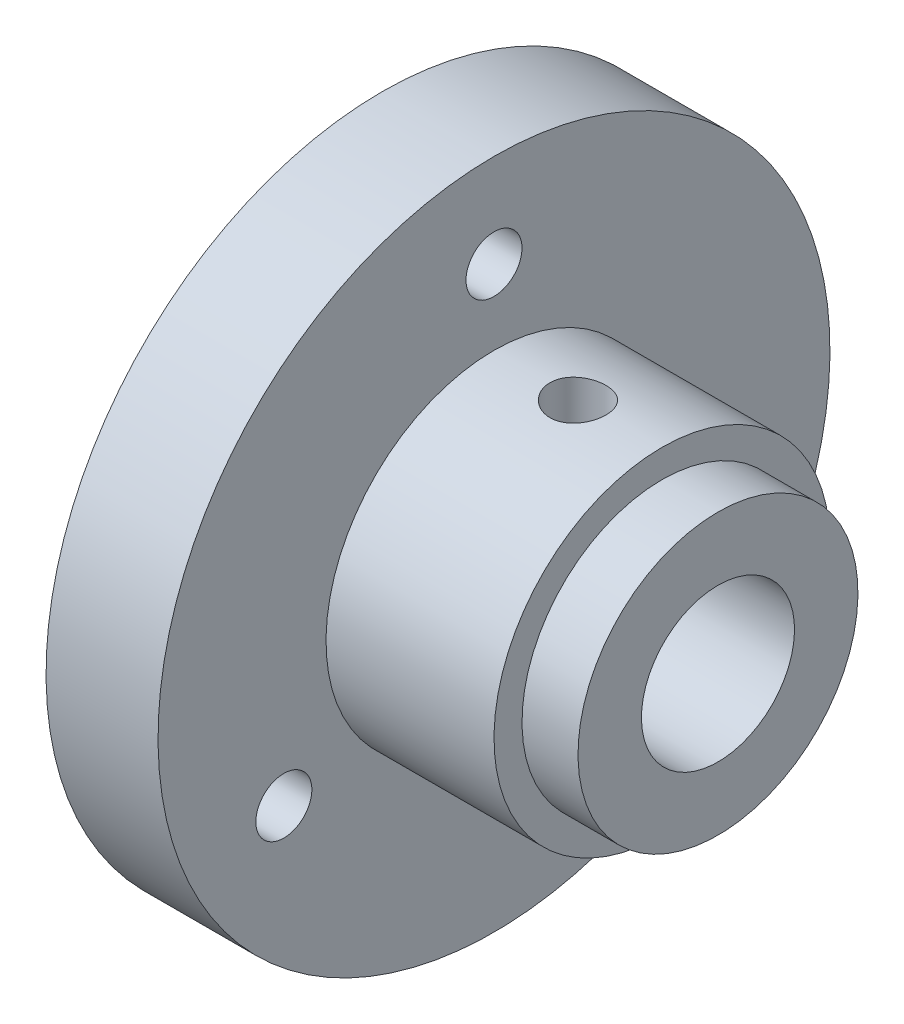
from build123d import *

# Parameters (mm, degrees)
ESQUISSE2_R             = 1.5
ENL_V_MAT_EXTRU_1_DEPTH = 7
ENL_V_MAT_EXTRU_2_REACH = 29
ESQUISSE3_R             = 1.5


with BuildPart() as part:
    # Esquisse1 → Révolution1 (revolve)
    with BuildSketch(Plane.XY):
        Polygon((0, 4.1), (-18, 4.1), (-18, 18), (-12, 18), (-12, 9), (-3, 9), (-3, 7.5), (0, 7.5), align=None)
    revolve(axis=Axis((0, 0, 0), (-1, 0, 0)))

    # Esquisse2 → Enlèv. mat.-Extru.1 (cut, through all)
    with BuildSketch(Plane(origin=(-12, 0, 0), x_dir=(0, 0, -1), z_dir=(1, 0, 0))):
        with Locations((0, 13)):
            Circle(ESQUISSE2_R)
        with Locations((11.258330249, -6.5)):
            Circle(ESQUISSE2_R)
        with Locations((-11.258330249, -6.5)):
            Circle(ESQUISSE2_R)
    extrude(amount=-ENL_V_MAT_EXTRU_1_DEPTH, mode=Mode.SUBTRACT)

    # Esquisse3 → Enlèv. mat.-Extru.2 (cut, up to next)
    with BuildSketch(Plane(origin=(0, 9, 0), x_dir=(1, 0, 0), z_dir=(0, 1, 0)), mode=Mode.PRIVATE) as enl_v_mat_extru_2_sk1:
        with Locations((-7.5, 0)):
            Circle(ESQUISSE3_R)
    enl_v_mat_extru_2_tool1 = extrude(enl_v_mat_extru_2_sk1.sketch, amount=-ENL_V_MAT_EXTRU_2_REACH, mode=Mode.PRIVATE) & part.part
    add(enl_v_mat_extru_2_tool1.solids().sort_by_distance((-7.5, 9, 0))[0], mode=Mode.SUBTRACT)


solid = part.part
